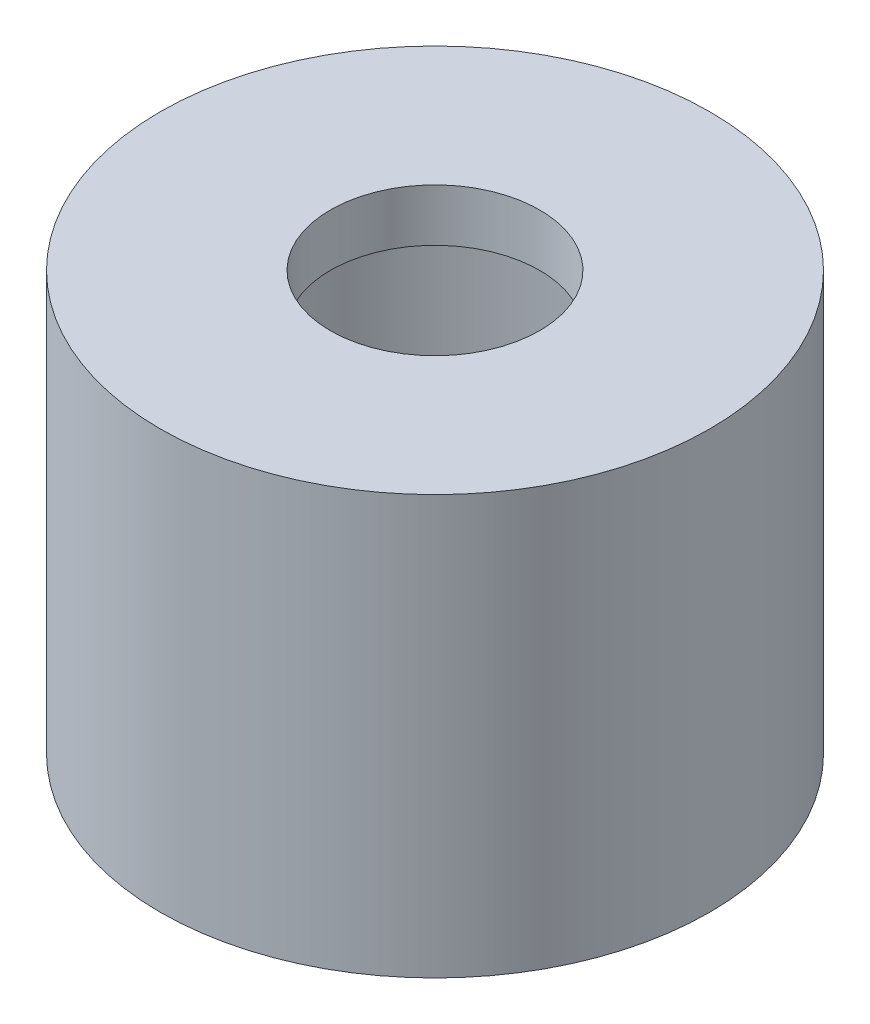
from build123d import *


with BuildPart() as part:
    # Esquisse1 → Révolution1 (revolve)
    with BuildSketch(Plane.XY):
        Polygon((-10.5, -3), (-4, -3), (-4, -5), (-8.5, -5), (-8.5, -19), (-10.5, -19), align=None)
    revolve(axis=Axis((0, 0, 0), (0, -1, 0)))


solid = part.part
